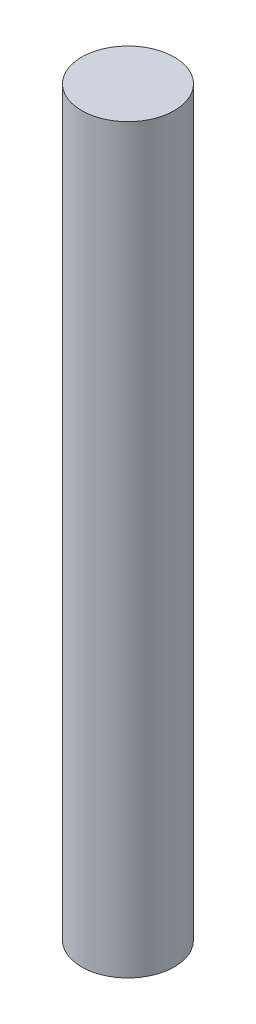
from build123d import *

# Parameters (mm, degrees)
SKETCH1_R           = 6.35
BOSS_EXTRUDE1_DEPTH = 101.6


with BuildPart() as part:
    # Sketch1 → Boss-Extrude1 (new body)
    with BuildSketch(Plane(origin=(0, 0, 0), x_dir=(1, 0, 0), z_dir=(0, 1, 0))):
        Circle(SKETCH1_R)
    extrude(amount=BOSS_EXTRUDE1_DEPTH)


solid = part.part
